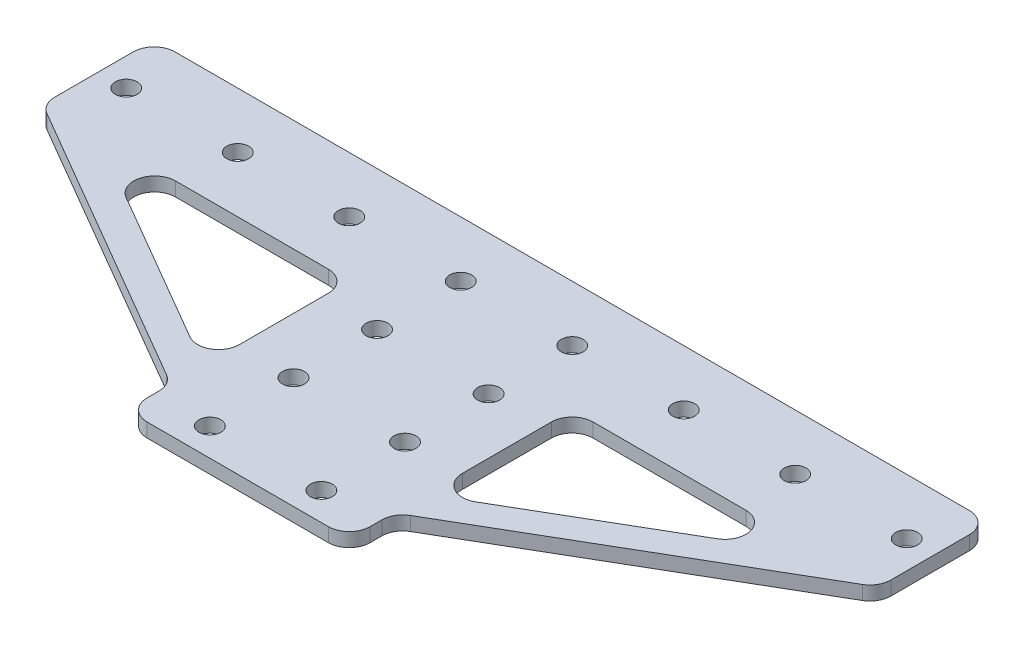
from build123d import *

# Parameters (mm, degrees)
SKETCH1_R           = 2.4892
BOSS_EXTRUDE1_DEPTH = 3.175
FILLET1_R           = 4.7625


with BuildPart() as part:
    # Sketch1 → Boss-Extrude1 (new body)
    with BuildSketch(Plane(origin=(0, 0, 0), x_dir=(1, 0, 0), z_dir=(0, 1, 0))):
        Polygon((0, 25.4), (0, 0), (69.85, -40.64), (69.85, -50.8), (120.65, -50.8), (120.65, -40.64), (190.5, 0), (190.5, 25.4), align=None)
        Polygon((120.65, -33.293424872), (120.65, 0), (177.873073998, 0), align=None, mode=Mode.SUBTRACT)
        Polygon((69.85, -33.293424872), (12.626926002, 0), (69.85, 0), align=None, mode=Mode.SUBTRACT)
        with Locations((6.35, 12.7)):
            Circle(SKETCH1_R, mode=Mode.SUBTRACT)
        with Locations((31.75, 12.7)):
            Circle(SKETCH1_R, mode=Mode.SUBTRACT)
        with Locations((57.15, 12.7)):
            Circle(SKETCH1_R, mode=Mode.SUBTRACT)
        with Locations((82.55, 12.7)):
            Circle(SKETCH1_R, mode=Mode.SUBTRACT)
        with Locations((107.95, 12.7)):
            Circle(SKETCH1_R, mode=Mode.SUBTRACT)
        with Locations((133.35, 12.7)):
            Circle(SKETCH1_R, mode=Mode.SUBTRACT)
        with Locations((158.75, 12.7)):
            Circle(SKETCH1_R, mode=Mode.SUBTRACT)
        with Locations((184.15, 12.7)):
            Circle(SKETCH1_R, mode=Mode.SUBTRACT)
        with Locations((107.95, -6.35)):
            Circle(SKETCH1_R, mode=Mode.SUBTRACT)
        with Locations((82.55, -6.35)):
            Circle(SKETCH1_R, mode=Mode.SUBTRACT)
        with Locations((82.55, -44.45)):
            Circle(SKETCH1_R, mode=Mode.SUBTRACT)
        with Locations((82.55, -25.4)):
            Circle(SKETCH1_R, mode=Mode.SUBTRACT)
        with Locations((107.95, -44.45)):
            Circle(SKETCH1_R, mode=Mode.SUBTRACT)
        with Locations((107.95, -25.4)):
            Circle(SKETCH1_R, mode=Mode.SUBTRACT)
    extrude(amount=BOSS_EXTRUDE1_DEPTH)

    # Fillet1
    fillet1_edges = [part.edges().sort_by_distance(p)[0] for p in [
        (120.65, 1.5875, 33.293424872),
        (177.873073998, 1.5875, 0),
        (120.65, 1.5875, 0),
        (69.85, 1.5875, 33.293424872),
        (69.85, 1.5875, 0),
        (12.626926002, 1.5875, 0),
        (120.65, 1.5875, 40.64),
        (120.65, 1.5875, 50.8),
        (69.85, 1.5875, 50.8),
        (69.85, 1.5875, 40.64),
        (0, 1.5875, 0),
        (0, 1.5875, -25.4),
        (190.5, 1.5875, -25.4),
        (190.5, 1.5875, 0),
    ]]
    fillet(fillet1_edges, radius=FILLET1_R)


solid = part.part
